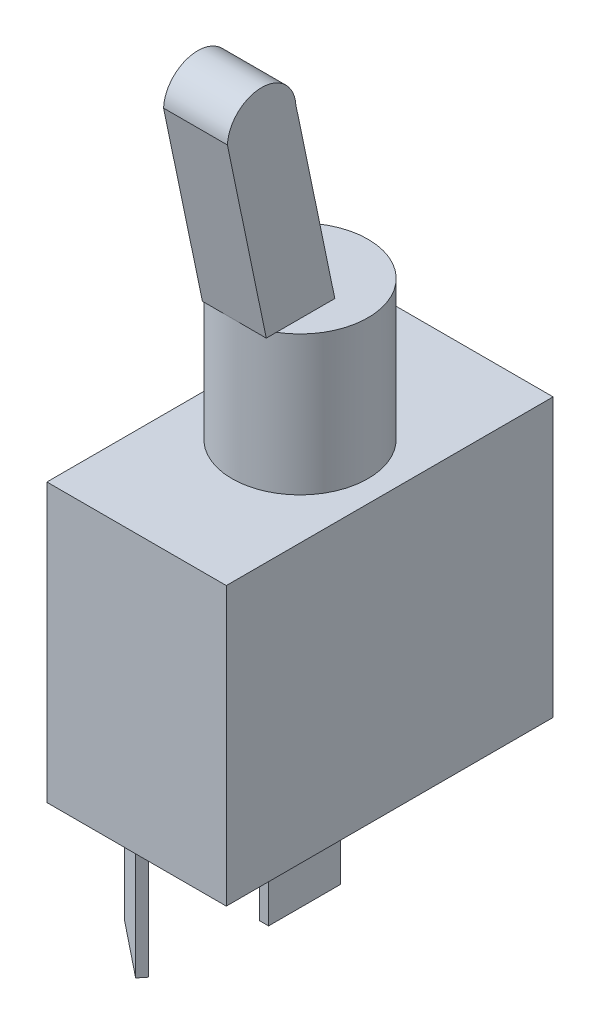
from build123d import *

# Parameters (mm, degrees)
SKETCH1_W               = 15.7
SKETCH1_H               = 28.6
BODY_DEPTH              = 24.3
SKETCH2_R               = 5.953125
PANEL_MOUNT_15_32_DEPTH = 12.2
SWITCH_DEPTH            = 3.048
SWITCH_DEPTH_BACK       = 2.54
SKETCH10_W              = 0.8
SKETCH10_H              = 6.3
CONNECTORS_DEPTH        = 10.8


with BuildPart() as part:
    # Sketch1 → Body (new body)
    with BuildSketch(Plane(origin=(0, 0, 0), x_dir=(1, 0, 0), z_dir=(0, 1, 0))):
        Rectangle(SKETCH1_W, SKETCH1_H)
    extrude(amount=BODY_DEPTH)

    # Sketch2 → Panel Mount  15/32 (add)
    with BuildSketch(Plane(origin=(0, 24.3, 0), x_dir=(1, 0, 0), z_dir=(0, 1, 0))):
        Circle(SKETCH2_R)
    extrude(amount=PANEL_MOUNT_15_32_DEPTH)

    # Sketch9 → Switch (add, two sides)
    with BuildSketch(Plane(origin=(0, 0, 0), x_dir=(0, 0, -1), z_dir=(1, 0, 0))) as switch_sk:
        with BuildLine():
            Line((0, 36.5), (-6, 36.5))
            Line((-6, 36.5), (-9.40084725, 52.842068887))
            ThreePointArc((-9.40084725, 52.842068887), (-6.42619484, 55.699919466), (-3.409982549, 52.885966675))
            Line((-3.409982549, 52.885966675), (0, 36.5))
        make_face()
    extrude(amount=SWITCH_DEPTH)
    extrude(switch_sk.sketch, amount=-SWITCH_DEPTH_BACK)

    # Sketch10 → Connectors (add)
    with BuildSketch(Plane.XZ):
        Polygon((-6.390931504, 8.976782117), (-5.891175466, 8.352087069), (-0.971701967, 12.287665869), (-1.471458005, 12.912360916), align=None)
        Rectangle(SKETCH10_W, SKETCH10_H)
    extrude(amount=CONNECTORS_DEPTH)


solid = part.part
